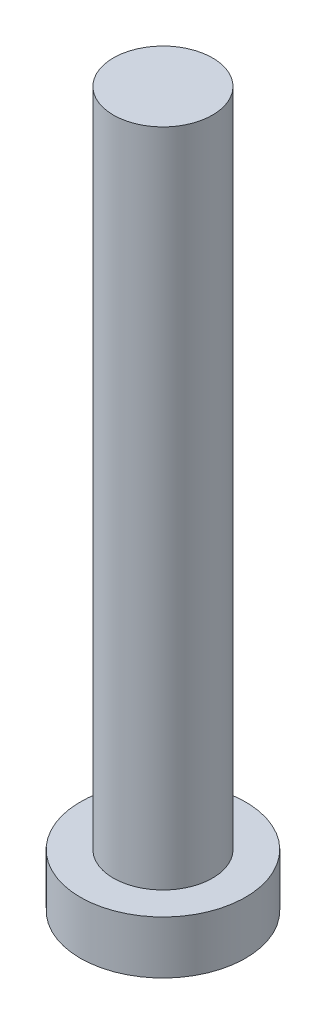
from build123d import *

# Parameters (mm, degrees)
SKETCH_1_R          = 2.5
EXTRUDE_1_DEPTH     = 1.6
SKETCH_2_R          = 1.5
EXTRUDE_2_DEPTH     = 20
CUT_EXTRUDE_1_DEPTH = 1


with BuildPart() as part:
    # 草图1 → 凸台-拉伸1 (new body)
    with BuildSketch(Plane(origin=(0, 0, 0), x_dir=(1, 0, 0), z_dir=(0, 1, 0))):
        Circle(SKETCH_1_R)
    extrude(amount=EXTRUDE_1_DEPTH)

    # 草图2 → 凸台-拉伸2 (add)
    with BuildSketch(Plane(origin=(0, 1.6, 0), x_dir=(1, 0, 0), z_dir=(0, 1, 0))):
        Circle(SKETCH_2_R)
    extrude(amount=EXTRUDE_2_DEPTH)

    # 草图3 → 切除-拉伸1 (cut)
    with BuildSketch(Plane.XZ):
        with BuildLine():
            Line((-0.5, 1), (-0.5, 1.75))
            Line((-0.5, 1.75), (0.5, 1.75))
            Line((0.5, 1.75), (0.5, 1))
            ThreePointArc((0.5, 1), (0.646446609, 0.646446609), (1, 0.5))
            Line((1, 0.5), (1.75, 0.5))
            Line((1.75, 0.5), (1.75, -0.5))
            Line((1.75, -0.5), (1, -0.5))
            ThreePointArc((1, -0.5), (0.646446609, -0.646446609), (0.5, -1))
            Line((0.5, -1), (0.5, -1.75))
            Line((0.5, -1.75), (-0.5, -1.75))
            Line((-0.5, -1.75), (-0.5, -1))
            ThreePointArc((-0.5, -1), (-0.646446609, -0.646446609), (-1, -0.5))
            Line((-1, -0.5), (-1.75, -0.5))
            Line((-1.75, -0.5), (-1.75, 0.5))
            Line((-1.75, 0.5), (-1, 0.5))
            ThreePointArc((-1, 0.5), (-0.646446609, 0.646446609), (-0.5, 1))
        make_face()
    extrude(amount=-CUT_EXTRUDE_1_DEPTH, mode=Mode.SUBTRACT)


solid = part.part
